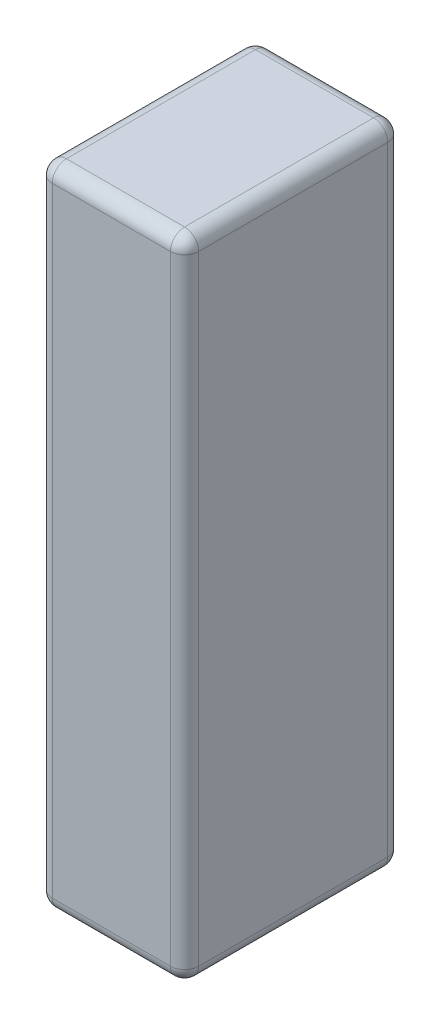
from build123d import *

# Parameters (mm, degrees)
SKETCH1_W           = 31
SKETCH1_H           = 46
BOSS_EXTRUDE1_DEPTH = 137
FILLET1_R           = 3


with BuildPart() as part:
    # Sketch1 → Boss-Extrude1 (new body)
    with BuildSketch(Plane(origin=(0, 0, 0), x_dir=(1, 0, 0), z_dir=(0, 1, 0))):
        with Locations((15.5, 23)):
            Rectangle(SKETCH1_W, SKETCH1_H)
    extrude(amount=BOSS_EXTRUDE1_DEPTH)

    # Fillet1
    fillet1_edges = [part.edges().sort_by_distance(p)[0] for p in [
        (31, 137, -23),
        (15.5, 137, -46),
        (0, 137, -23),
        (15.5, 0, -46),
        (31, 0, -23),
        (15.5, 0, 0),
        (0, 0, -23),
        (15.5, 137, 0),
        (0, 68.5, -46),
        (31, 68.5, -46),
        (31, 68.5, 0),
        (0, 68.5, 0),
    ]]
    fillet(fillet1_edges, radius=FILLET1_R)


solid = part.part
